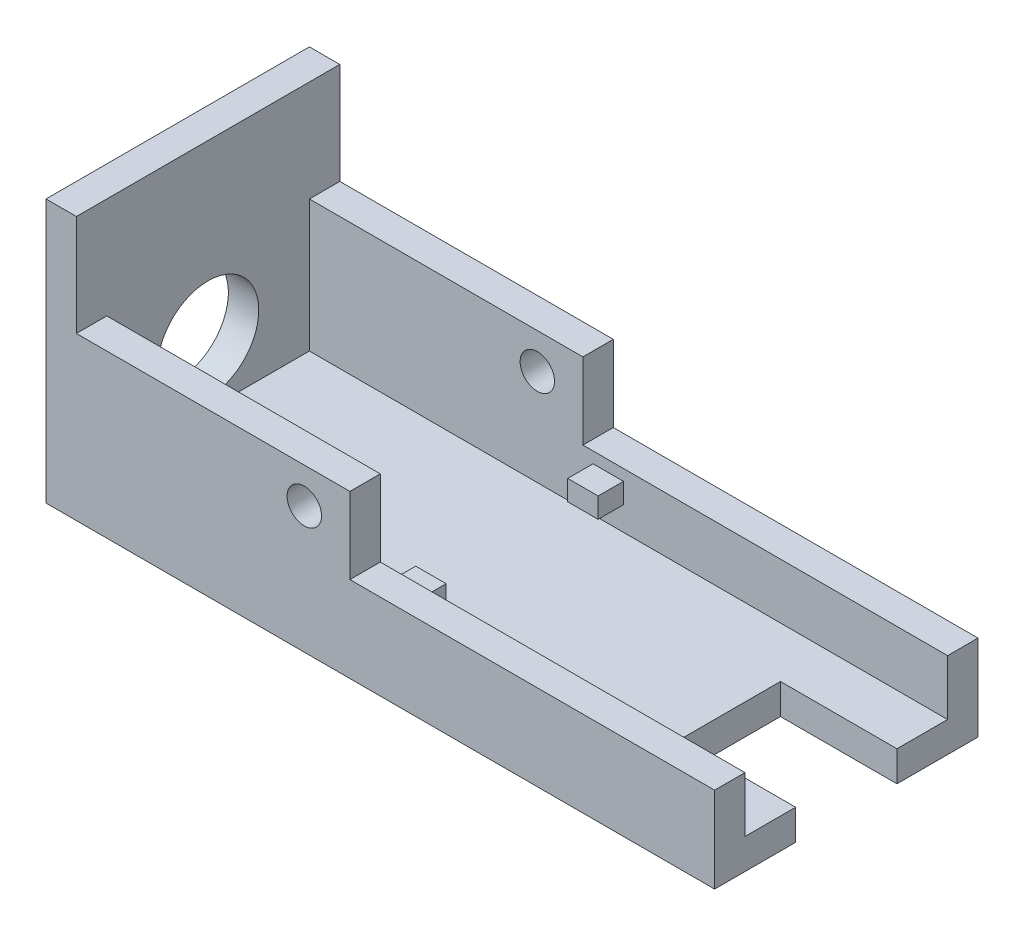
from build123d import *

# Parameters (mm, degrees)
SKETCH1_W               = 66
SKETCH1_H               = 26
BOSS_EXTRUDE1_DEPTH     = 3
BOSS_EXTRUDE2_START     = 3
BOSS_EXTRUDE2_DEPTH     = 3
BOSS_EXTRUDE3_DEPTH     = 10
BOSS_EXTRUDE4_START     = 10
BOSS_EXTRUDE4_DEPTH     = 10
SKETCH2_4_W             = 36
SKETCH2_4_H             = 3
BOSS_EXTRUDE5_DEPTH     = 2.46
SKETCH3_W               = 3
SKETCH3_H               = 2
BOSS_EXTRUDE6_DEPTH     = 2.5
SKETCH4_W               = 11.5
SKETCH4_H               = 10
CUT_EXTRUDE1_DEPTH      = 1
CUT_EXTRUDE1_DEPTH_BACK = 27
M3_CLEARANCE_HOLE1_D    = 3.4
CUT_EXTRUDE2_REACH      = 68
SKETCH8_R               = 5


with BuildPart() as part:
    # Sketch1 → Boss-Extrude1 (new body)
    with BuildSketch(Plane(origin=(0, 0, 0), x_dir=(1, 0, 0), z_dir=(0, 1, 0))):
        Rectangle(SKETCH1_W, SKETCH1_H)
    extrude(amount=BOSS_EXTRUDE1_DEPTH)

    # Sketch1_3 → Boss-Extrude2 (add)
    with BuildSketch(Plane(origin=(0, 0, 0), x_dir=(1, 0, 0), z_dir=(0, 1, 0)).offset(BOSS_EXTRUDE2_START)):
        Polygon((-30, 10), (30, 10), (33, 10), (33, 13), (-33, 13), (-33, -13), (33, -13), (33, -10), (30, -10), (-30, -10), align=None)
    extrude(amount=BOSS_EXTRUDE2_DEPTH)

    # Sketch2 → Boss-Extrude3 (add)
    with BuildSketch(Plane(origin=(0, 6, 0), x_dir=(1, 0, 0), z_dir=(0, 1, 0))):
        Polygon((-3, 10), (-3, 13), (-33, 13), (-33, -13), (-3, -13), (-3, -10), (-30, -10), (-30, 10), align=None)
    extrude(amount=BOSS_EXTRUDE3_DEPTH)

    # Sketch2_3 → Boss-Extrude4 (add)
    with BuildSketch(Plane(origin=(0, 6, 0), x_dir=(1, 0, 0), z_dir=(0, 1, 0)).offset(BOSS_EXTRUDE4_START)):
        Polygon((-30, 10), (-30, 13), (-33, 13), (-33, -13), (-30, -13), (-30, -10), align=None)
    extrude(amount=BOSS_EXTRUDE4_DEPTH)

    # Sketch2_4 → Boss-Extrude5 (add)
    with BuildSketch(Plane(origin=(0, 6, 0), x_dir=(1, 0, 0), z_dir=(0, 1, 0))):
        with Locations((15, 11.5)):
            Rectangle(SKETCH2_4_W, SKETCH2_4_H)
        with Locations((15, -11.5)):
            Rectangle(SKETCH2_4_W, SKETCH2_4_H)
    extrude(amount=BOSS_EXTRUDE5_DEPTH)

    # Sketch3 → Boss-Extrude6 (add)
    with BuildSketch(Plane.XY.offset(-10)):
        with Locations((-0.5, 6.36)):
            Rectangle(SKETCH3_W, SKETCH3_H)
    boss_extrude6 = extrude(amount=BOSS_EXTRUDE6_DEPTH)

    # Mirror1: Boss-Extrude6 across plane
    add(boss_extrude6.mirror(Plane.XY))

    # Sketch4 → Cut-Extrude1 (cut, two sides)
    with BuildSketch(Plane.XZ) as cut_extrude1_sk:
        with Locations((27.25, 0)):
            Rectangle(SKETCH4_W, SKETCH4_H)
    extrude(amount=CUT_EXTRUDE1_DEPTH, mode=Mode.SUBTRACT)
    extrude(cut_extrude1_sk.sketch, amount=-CUT_EXTRUDE1_DEPTH_BACK, mode=Mode.SUBTRACT)

    # M3 Clearance Hole1 (through all)
    with Locations(Plane.XY.offset(13)):
        with Locations((-7.5, 12.5)):
            Hole(M3_CLEARANCE_HOLE1_D / 2)

    # Sketch8 → Cut-Extrude2 (cut, up to next)
    with BuildSketch(Plane.ZY.offset(33), mode=Mode.PRIVATE) as cut_extrude2_sk1:
        with Locations((0, 9)):
            Circle(SKETCH8_R)
    cut_extrude2_tool1 = extrude(cut_extrude2_sk1.sketch, amount=-CUT_EXTRUDE2_REACH, mode=Mode.PRIVATE) & part.part
    add(cut_extrude2_tool1.solids().sort_by_distance((-33, 9, 0))[0], mode=Mode.SUBTRACT)


solid = part.part
